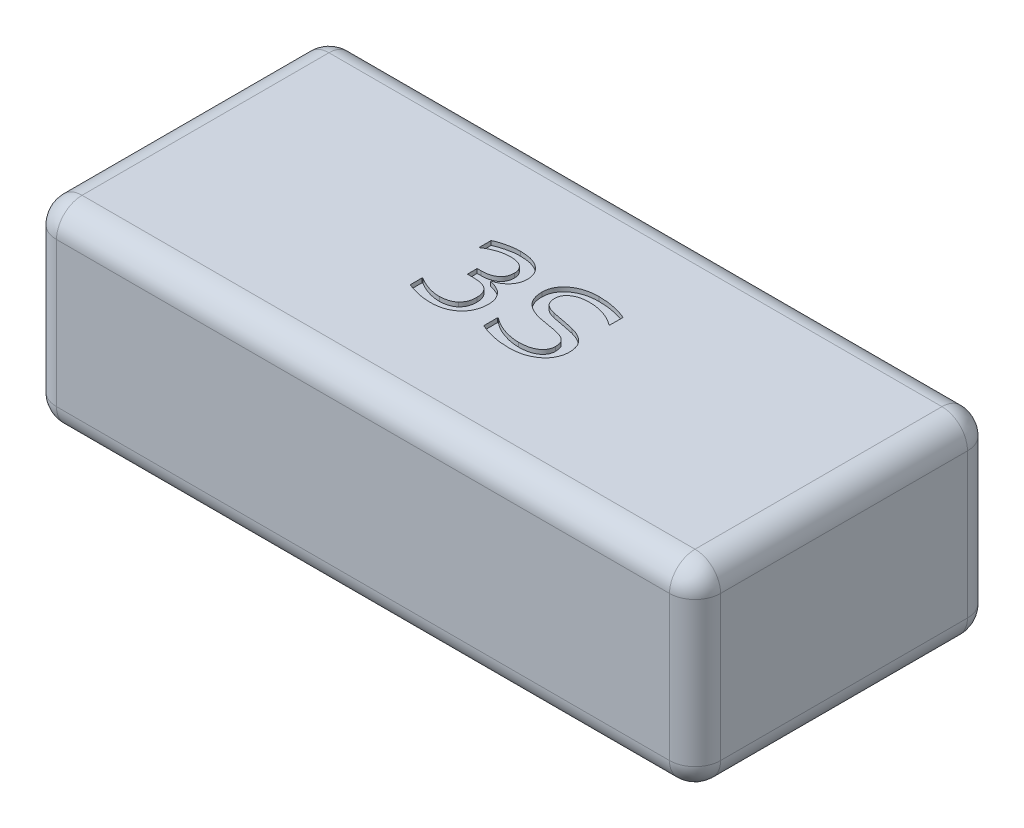
from build123d import *

# Parameters (mm, degrees)
SKICA1_W                 = 78
SKICA1_H                 = 35
P_IDAT_VYSUNUT_M1_DEPTH  = 23
ZAOBLIT1_R               = 3
ODEBRAT_VYSUNUT_M1_DEPTH = 0.5


with BuildPart() as part:
    # Skica1 → Přidat vysunutím1 (new body)
    with BuildSketch(Plane(origin=(0, 0, 0), x_dir=(1, 0, 0), z_dir=(0, 1, 0))):
        Rectangle(SKICA1_W, SKICA1_H)
    extrude(amount=P_IDAT_VYSUNUT_M1_DEPTH)

    # Zaoblit1
    zaoblit1_edges = [part.edges().sort_by_distance(p)[0] for p in [
        (39, 23, 0),
        (0, 23, -17.5),
        (-39, 23, 0),
        (0, 0, -17.5),
        (39, 0, 0),
        (0, 0, 17.5),
        (-39, 0, 0),
        (0, 23, 17.5),
        (-39, 11.5, -17.5),
        (39, 11.5, -17.5),
        (39, 11.5, 17.5),
        (-39, 11.5, 17.5),
    ]]
    fillet(zaoblit1_edges, radius=ZAOBLIT1_R)

    # Skica2 → Odebrat vysunutím1 (cut)
    with BuildSketch(Plane(origin=(0, 23, 0), x_dir=(1, 0, 0), z_dir=(0, 1, 0))):
        with BuildLine():
            add(Edge.make_bspline(
                [(-1.782361882, 0.073352781), (-1.729838113, 0.022972497), (-1.623845128, -0.078694937), (-1.483543013, -0.252135199), (-1.358427222, -0.443985844), (-1.246194522, -0.654552847), (-1.152930789, -0.891803328), (-1.089399078, -1.159962089), (-1.052580916, -1.45977402), (-1.047363786, -1.669680055), (-1.04462454, -1.77989089)],
                knots=[0, 0, 0, 0, 0.000218174, 0.000440275, 0.000667383, 0.000904494, 0.001154987, 0.001429858, 0.001728906, 0.002059496, 0.002059496, 0.002059496, 0.002059496], degree=3))
            add(Edge.make_bspline(
                [(-1.04462454, -1.77989089), (-1.04774886, -1.8921126), (-1.053877005, -2.112228024), (-1.099746924, -2.436079367), (-1.179307124, -2.74468389), (-1.287933389, -3.038431867), (-1.425672214, -3.313798537), (-1.586109658, -3.573369059), (-1.774449699, -3.813734665), (-1.918009686, -3.958201036), (-1.990035932, -4.030682029)],
                knots=[0, 0, 0, 0, 0.000336606, 0.000660231, 0.000978756, 0.001291037, 0.001597967, 0.001900914, 0.002205181, 0.002511544, 0.002511544, 0.002511544, 0.002511544], degree=3))
            add(Edge.make_bspline(
                [(-1.990035932, -4.030682029), (-2.076149985, -4.10584668), (-2.248294833, -4.256103313), (-2.535949464, -4.446597154), (-2.845932299, -4.604144599), (-3.175471353, -4.734119283), (-3.525652033, -4.828821148), (-3.891589009, -4.90094646), (-4.274804432, -4.942592237), (-4.535428248, -4.94775461), (-4.668042262, -4.950381396)],
                knots=[0, 0, 0, 0, 0.00034263, 0.00068493, 0.00103168, 0.001384275, 0.001745616, 0.002118381, 0.002502359, 0.002900147, 0.002900147, 0.002900147, 0.002900147], degree=3))
            add(Edge.make_bspline(
                [(-4.668042262, -4.950381396), (-4.806585854, -4.948331058), (-5.08221197, -4.944252006), (-5.494189971, -4.904176594), (-5.902454583, -4.84406869), (-6.301405607, -4.758904448), (-6.679648102, -4.659106133), (-7.027814217, -4.552309379), (-7.341453014, -4.443377238), (-7.535005846, -4.360686521), (-7.626903021, -4.3214257)],
                knots=[0, 0, 0, 0, 0.000415518, 0.000826653, 0.001240633, 0.00165298, 0.00204972, 0.002413838, 0.002745385, 0.003045106, 0.003045106, 0.003045106, 0.003045106], degree=3))
            Line((-7.626903021, -4.3214257), (-7.626903021, -2.92506494))
            Line((-7.626903021, -2.92506494), (-7.526032768, -2.92506494))
            add(Edge.make_bspline(
                [(-7.526032768, -2.92506494), (-7.427934696, -2.987061246), (-7.227847628, -3.113512855), (-6.906214232, -3.2815255), (-6.558648534, -3.431341152), (-6.192132096, -3.563442351), (-5.816538511, -3.67563096), (-5.440933092, -3.75065725), (-5.07227658, -3.802041745), (-4.828416218, -3.808126358), (-4.707599224, -3.81114089)],
                knots=[0, 0, 0, 0, 0.000348034, 0.000709872, 0.001087226, 0.001482638, 0.001878207, 0.002261834, 0.002630802, 0.002993094, 0.002993094, 0.002993094, 0.002993094], degree=3))
            add(Edge.make_bspline(
                [(-4.707599224, -3.81114089), (-4.636302695, -3.809871242), (-4.490544685, -3.807275586), (-4.269991091, -3.777159487), (-4.042635788, -3.733758831), (-3.813558262, -3.673770256), (-3.590518545, -3.597486405), (-3.386241544, -3.499615637), (-3.201703855, -3.388647594), (-3.095860886, -3.297735916), (-3.04422897, -3.253387725)],
                knots=[0, 0, 0, 0, 0.000213754, 0.000436997, 0.000666632, 0.000907937, 0.001146889, 0.001372485, 0.001586541, 0.001790413, 0.001790413, 0.001790413, 0.001790413], degree=3))
            add(Edge.make_bspline(
                [(-3.04422897, -3.253387725), (-2.994855417, -3.203720234), (-2.898015627, -3.106303923), (-2.776199302, -2.943686892), (-2.669677936, -2.7773926), (-2.582488215, -2.600151407), (-2.516394314, -2.405458874), (-2.469871319, -2.189862085), (-2.442588135, -1.950680851), (-2.438936736, -1.783920527), (-2.437029603, -1.696821269)],
                knots=[0, 0, 0, 0, 0.000209857, 0.000411607, 0.000608052, 0.000801771, 0.001002549, 0.001223298, 0.00146225, 0.001723513, 0.001723513, 0.001723513, 0.001723513], degree=3))
            add(Edge.make_bspline(
                [(-2.437029603, -1.696821269), (-2.43838445, -1.610976018), (-2.440991167, -1.445810191), (-2.475721239, -1.210676021), (-2.527682247, -0.997585145), (-2.604202201, -0.808255684), (-2.696990081, -0.638179088), (-2.808801919, -0.489029945), (-2.936172633, -0.357936449), (-3.033263906, -0.286654307), (-3.081808084, -0.251014307)],
                knots=[0, 0, 0, 0, 0.00025731, 0.000495064, 0.00071141, 0.00091378, 0.001105886, 0.001291013, 0.001471431, 0.001651839, 0.001651839, 0.001651839, 0.001651839], degree=3))
            add(Edge.make_bspline(
                [(-3.081808084, -0.251014307), (-3.134449508, -0.217341413), (-3.240842552, -0.149285469), (-3.418327359, -0.070612337), (-3.610544754, -0.00738885), (-3.892614646, 0.0550933), (-4.272294164, 0.101402738), (-4.582857772, 0.10899163), (-4.743200489, 0.112909743)],
                knots=[0, 0, 0, 0, 0.000187239, 0.000378426, 0.000580448, 0.000793477, 0.001244136, 0.00172516, 0.00172516, 0.00172516, 0.00172516], degree=3))
            Line((-4.743200489, 0.112909743), (-5.348422008, 0.112909743))
            Line((-5.348422008, 0.112909743), (-5.348422008, 1.25215025))
            Line((-5.348422008, 1.25215025), (-4.887583401, 1.25215025))
            add(Edge.make_bspline(
                [(-4.887583401, 1.25215025), (-4.805765797, 1.252823475), (-4.64643157, 1.254134536), (-4.414783099, 1.277732751), (-4.194908841, 1.309695556), (-3.988359918, 1.359909862), (-3.79346063, 1.420437884), (-3.611483311, 1.495626976), (-3.4437636, 1.587706783), (-3.286591505, 1.68938023), (-3.146081491, 1.805770162), (-3.023533371, 1.935813071), (-2.920653616, 2.079205771), (-2.834153796, 2.234608124), (-2.769072018, 2.403846436), (-2.72426586, 2.585320709), (-2.695792507, 2.778815866), (-2.692097538, 2.912120631), (-2.69019416, 2.98078949)],
                knots=[0, 0, 0, 0, 0.000245325, 0.000477754, 0.0006979, 0.000911379, 0.001114675, 0.001309721, 0.001500878, 0.001687939, 0.001870523, 0.002046829, 0.00222249, 0.002398652, 0.002578995, 0.002764639, 0.002958478, 0.003164412, 0.003164412, 0.003164412, 0.003164412], degree=3))
            add(Edge.make_bspline(
                [(-2.69019416, 2.98078949), (-2.692172708, 3.041537268), (-2.696001162, 3.159083085), (-2.723391631, 3.330342307), (-2.773490133, 3.488875325), (-2.84112444, 3.636111755), (-2.924760187, 3.771683129), (-3.023907947, 3.895115575), (-3.139652049, 4.004803849), (-3.226090759, 4.0669285), (-3.269703654, 4.098273667)],
                knots=[0, 0, 0, 0, 0.000182231, 0.000352613, 0.000518387, 0.000679457, 0.000837536, 0.00099507, 0.001153162, 0.001314159, 0.001314159, 0.001314159, 0.001314159], degree=3))
            add(Edge.make_bspline(
                [(-3.269703654, 4.098273667), (-3.317325084, 4.126899122), (-3.412258098, 4.183963783), (-3.563631564, 4.252793959), (-3.719832344, 4.308336058), (-3.940695438, 4.364799078), (-4.241239745, 4.407018605), (-4.488569857, 4.413368795), (-4.618596059, 4.416707212)],
                knots=[0, 0, 0, 0, 0.000166574, 0.000332065, 0.000497839, 0.000663341, 0.00101522, 0.001405263, 0.001405263, 0.001405263, 0.001405263], degree=3))
            add(Edge.make_bspline(
                [(-4.618596059, 4.416707212), (-4.725530711, 4.414024232), (-4.944203097, 4.408537764), (-5.276387423, 4.363043414), (-5.618227682, 4.288191652), (-5.967219577, 4.189325563), (-6.315090875, 4.05967434), (-6.658068241, 3.910864785), (-6.989683493, 3.734220674), (-7.200580006, 3.598692914), (-7.306491629, 3.530631262)],
                knots=[0, 0, 0, 0, 0.00032071, 0.000655826, 0.001003798, 0.00137002, 0.001742959, 0.002116688, 0.002490967, 0.00286855, 0.00286855, 0.00286855, 0.00286855], degree=3))
            Line((-7.306491629, 3.530631262), (-7.373738464, 3.530631262))
            Line((-7.373738464, 3.530631262), (-7.373738464, 4.926992022))
            add(Edge.make_bspline(
                [(-7.373738464, 4.926992022), (-7.288493829, 4.96631843), (-7.107368847, 5.049877883), (-6.809074611, 5.159437281), (-6.471065405, 5.262462019), (-6.102087658, 5.361886117), (-5.716038907, 5.449233834), (-5.327374326, 5.508923974), (-4.945145464, 5.549588989), (-4.692538159, 5.553838656), (-4.567172008, 5.555947718)],
                knots=[0, 0, 0, 0, 0.00028155, 0.000598228, 0.000952313, 0.001341406, 0.001744504, 0.002138935, 0.002520536, 0.002896515, 0.002896515, 0.002896515, 0.002896515], degree=3))
            add(Edge.make_bspline(
                [(-4.567172008, 5.555947718), (-4.449114007, 5.554656958), (-4.219949465, 5.552151441), (-3.887014973, 5.526341668), (-3.576014964, 5.482819486), (-3.284083234, 5.424220291), (-3.010078297, 5.345084827), (-2.750682888, 5.245325235), (-2.50486951, 5.12611327), (-2.352433603, 5.028707923), (-2.276823907, 4.980393921)],
                knots=[0, 0, 0, 0, 0.000354123, 0.000687395, 0.001000951, 0.00129575, 0.001579928, 0.00185541, 0.002128732, 0.002397727, 0.002397727, 0.002397727, 0.002397727], degree=3))
            add(Edge.make_bspline(
                [(-2.276823907, 4.980393921), (-2.199403259, 4.924997503), (-2.047943911, 4.816624538), (-1.851175197, 4.62305402), (-1.681012749, 4.415035056), (-1.542132605, 4.187814436), (-1.431415384, 3.94299795), (-1.35235058, 3.679147313), (-1.306832427, 3.395076543), (-1.300859756, 3.199836736), (-1.297789097, 3.099460376)],
                knots=[0, 0, 0, 0, 0.000285208, 0.000557958, 0.00082515, 0.001089739, 0.001354423, 0.001629116, 0.001913631, 0.00221468, 0.00221468, 0.00221468, 0.00221468], degree=3))
            add(Edge.make_bspline(
                [(-1.297789097, 3.099460376), (-1.299999366, 3.02951396), (-1.304351321, 2.891791517), (-1.329597478, 2.68815606), (-1.376098234, 2.492646166), (-1.437337923, 2.302106187), (-1.518054737, 2.119085636), (-1.61847153, 1.943526774), (-1.735705783, 1.774831469), (-1.869138182, 1.614468659), (-2.014936462, 1.464653666), (-2.169332302, 1.329104739), (-2.327666713, 1.204672388), (-2.494439727, 1.097182502), (-2.669289187, 1.007756015), (-2.847689477, 0.926614894), (-3.033862225, 0.86305942), (-3.161946941, 0.833718286), (-3.226190996, 0.819001516)],
                knots=[0, 0, 0, 0, 0.000209885, 0.000413257, 0.000614279, 0.000811926, 0.001012947, 0.001213131, 0.001417778, 0.001628472, 0.001838273, 0.002044245, 0.002244428, 0.002441936, 0.002638332, 0.002833127, 0.003029522, 0.003227159, 0.003227159, 0.003227159, 0.003227159], degree=3))
            Line((-3.226190996, 0.819001516), (-3.226190996, 0.724064807))
            add(Edge.make_bspline(
                [(-3.226190996, 0.724064807), (-3.170627411, 0.713663156), (-3.053880131, 0.691807755), (-2.875329823, 0.640993631), (-2.684363945, 0.577622448), (-2.486921648, 0.499830881), (-2.289927635, 0.411118738), (-2.104354753, 0.310847002), (-1.933737493, 0.200391356), (-1.832326708, 0.115284637), (-1.782361882, 0.073352781)],
                knots=[0, 0, 0, 0, 0.000169507, 0.00035616, 0.000556304, 0.000773003, 0.000992508, 0.001204027, 0.00140535, 0.001600877, 0.001600877, 0.001600877, 0.001600877], degree=3))
        make_face()
        with BuildLine():
            add(Edge.make_bspline(
                [(8.575628624, -1.87284975), (8.571802335, -1.971256946), (8.564128606, -2.168615264), (8.513955827, -2.464579301), (8.42484972, -2.757345257), (8.306972164, -3.046302901), (8.161211464, -3.325022158), (7.979763381, -3.580385288), (7.777628956, -3.819965693), (7.619018375, -3.956214465), (7.539236219, -4.024748484)],
                knots=[0, 0, 0, 0, 0.000295236, 0.000592105, 0.000897489, 0.001211518, 0.001527393, 0.001838494, 0.002149777, 0.002464827, 0.002464827, 0.002464827, 0.002464827], degree=3))
            add(Edge.make_bspline(
                [(7.539236219, -4.024748484), (7.446819168, -4.09502879), (7.26111215, -4.236253226), (6.957030788, -4.419152715), (6.630564547, -4.57588552), (6.281219737, -4.713175686), (5.901196754, -4.820362121), (5.486800498, -4.896374004), (5.035625383, -4.941645911), (4.722888958, -4.947396944), (4.560596979, -4.950381396)],
                knots=[0, 0, 0, 0, 0.000348124, 0.000699536, 0.001062216, 0.001433551, 0.001824225, 0.002244731, 0.002696001, 0.003182809, 0.003182809, 0.003182809, 0.003182809], degree=3))
            add(Edge.make_bspline(
                [(4.560596979, -4.950381396), (4.384492655, -4.948423761), (4.04109028, -4.944606384), (3.539384315, -4.905631187), (3.065122166, -4.845729103), (2.613256955, -4.759855655), (2.174433677, -4.64593085), (1.73653348, -4.511241774), (1.293342082, -4.356084365), (1.001837703, -4.233322355), (0.854109637, -4.171109244)],
                knots=[0, 0, 0, 0, 0.000528219, 0.001030023, 0.00150865, 0.00196172, 0.002408806, 0.002868024, 0.003335943, 0.003816723, 0.003816723, 0.003816723, 0.003816723], degree=3))
            Line((0.854109637, -4.171109244), (0.854109637, -2.545318105))
            Line((0.854109637, -2.545318105), (0.949046346, -2.545318105))
            add(Edge.make_bspline(
                [(0.949046346, -2.545318105), (1.078391891, -2.643623536), (1.338461345, -2.841281984), (1.765969784, -3.090646944), (2.219741556, -3.309983593), (2.698233811, -3.487698594), (3.181833345, -3.631902225), (3.658469122, -3.731121815), (4.118833845, -3.800314264), (4.421908873, -3.80757932), (4.570486219, -3.81114089)],
                knots=[0, 0, 0, 0, 0.000486993, 0.000979175, 0.001481646, 0.001997405, 0.00250872, 0.002994003, 0.003457208, 0.003902663, 0.003902663, 0.003902663, 0.003902663], degree=3))
            add(Edge.make_bspline(
                [(4.570486219, -3.81114089), (4.670732225, -3.809517389), (4.865534495, -3.806362535), (5.149637377, -3.78497088), (5.416390175, -3.747262259), (5.6666042, -3.696879161), (5.899510418, -3.629462761), (6.115143549, -3.546558068), (6.314040672, -3.449763355), (6.494965011, -3.338610358), (6.656977019, -3.215543426), (6.795893709, -3.079202563), (6.917237892, -2.936518117), (7.014245379, -2.780991843), (7.090515263, -2.615554342), (7.143034753, -2.439671083), (7.178960287, -2.254714905), (7.181784943, -2.12750971), (7.183223561, -2.062723168)],
                knots=[0, 0, 0, 0, 0.000300737, 0.000584405, 0.000854046, 0.001108505, 0.001349486, 0.001580522, 0.001800775, 0.002012109, 0.002216632, 0.002409652, 0.002595022, 0.00277721, 0.002957758, 0.003139817, 0.003326804, 0.003520886, 0.003520886, 0.003520886, 0.003520886], degree=3))
            add(Edge.make_bspline(
                [(7.183223561, -2.062723168), (7.181773488, -2.008640518), (7.178957059, -1.903597611), (7.166186968, -1.751333392), (7.140740003, -1.609446448), (7.102404477, -1.479645068), (7.058309208, -1.359108571), (6.999523981, -1.251724449), (6.932953396, -1.153930245), (6.825755405, -1.03770902), (6.66445558, -0.907480291), (6.432298051, -0.77581538), (6.160149327, -0.657953674), (5.95976688, -0.601298646), (5.854109637, -0.5714257)],
                knots=[0, 0, 0, 0, 0.000162292, 0.000315214, 0.000457976, 0.000593816, 0.000720907, 0.000842138, 0.000960098, 0.001074915, 0.001315246, 0.001578486, 0.00187351, 0.002202583, 0.002202583, 0.002202583, 0.002202583], degree=3))
            add(Edge.make_bspline(
                [(5.854109637, -0.5714257), (5.677957344, -0.527284345), (5.313512692, -0.435959502), (4.738024667, -0.346295768), (4.125729997, -0.248878662), (3.70789079, -0.165449216), (3.492559004, -0.122454181)],
                knots=[0, 0, 0, 0, 0.000544512, 0.001126551, 0.001745974, 0.002404624, 0.002404624, 0.002404624, 0.002404624], degree=3))
            add(Edge.make_bspline(
                [(3.492559004, -0.122454181), (3.384107921, -0.098037639), (3.172256061, -0.050341575), (2.868607498, 0.040898527), (2.586449092, 0.143605765), (2.325624058, 0.258335901), (2.086535342, 0.386090692), (1.868785197, 0.527642867), (1.672683591, 0.681059688), (1.498798619, 0.849122678), (1.346001452, 1.029088345), (1.214327548, 1.222829167), (1.103049774, 1.429648607), (1.012277518, 1.649849171), (0.940733358, 1.882904091), (0.889395879, 2.128435058), (0.859554436, 2.387351767), (0.85595248, 2.564044528), (0.854109637, 2.654444553)],
                knots=[0, 0, 0, 0, 0.000333413, 0.000651299, 0.000950393, 0.00123375, 0.001505414, 0.001762702, 0.002011981, 0.00225117, 0.002486941, 0.002718991, 0.002952611, 0.003190258, 0.003432373, 0.003682959, 0.003941785, 0.004212931, 0.004212931, 0.004212931, 0.004212931], degree=3))
            add(Edge.make_bspline(
                [(0.854109637, 2.654444553), (0.856647202, 2.758201044), (0.861642155, 2.96243572), (0.916175387, 3.2607487), (0.99777036, 3.546566285), (1.118157658, 3.816238165), (1.26979425, 4.072037627), (1.455546533, 4.313235968), (1.676264533, 4.5383088), (1.928106146, 4.747281036), (2.203731578, 4.937405102), (2.50159006, 5.102516635), (2.816442845, 5.243207734), (3.150111548, 5.35784649), (3.501421779, 5.447014496), (3.871240674, 5.508994978), (4.258357726, 5.55052501), (4.522905835, 5.554119031), (4.657511536, 5.555947718)],
                knots=[0, 0, 0, 0, 0.000310925, 0.000612026, 0.000906805, 0.001200807, 0.001495234, 0.001797074, 0.002111776, 0.002438959, 0.002777454, 0.003114792, 0.003459199, 0.003810722, 0.004171938, 0.004545222, 0.004934894, 0.005338549, 0.005338549, 0.005338549, 0.005338549], degree=3))
            add(Edge.make_bspline(
                [(4.657511536, 5.555947718), (4.83163302, 5.553896651), (5.17370515, 5.549867206), (5.675530084, 5.511512287), (6.155817733, 5.449326466), (6.612070501, 5.35912709), (7.044465426, 5.25208901), (7.452328334, 5.133626404), (7.835178107, 5.004586904), (8.077700994, 4.904541409), (8.195881789, 4.85578949)],
                knots=[0, 0, 0, 0, 0.000522287, 0.001026064, 0.001508869, 0.001974341, 0.002420463, 0.00284483, 0.003248258, 0.003631695, 0.003631695, 0.003631695, 0.003631695], degree=3))
            Line((8.195881789, 4.85578949), (8.195881789, 3.277466705))
            Line((8.195881789, 3.277466705), (8.10094508, 3.277466705))
            add(Edge.make_bspline(
                [(8.10094508, 3.277466705), (7.998486781, 3.358365232), (7.786850846, 3.525467707), (7.423489765, 3.736823092), (7.017886551, 3.930218818), (6.573165062, 4.099175305), (6.10523285, 4.241365483), (5.623366171, 4.341639059), (5.136576017, 4.405842744), (4.809344579, 4.413084477), (4.645644447, 4.416707212)],
                knots=[0, 0, 0, 0, 0.000391219, 0.000808095, 0.001257502, 0.001738318, 0.002233903, 0.002723055, 0.003213454, 0.003704359, 0.003704359, 0.003704359, 0.003704359], degree=3))
            add(Edge.make_bspline(
                [(4.645644447, 4.416707212), (4.557268529, 4.414902922), (4.384911499, 4.411384066), (4.133097305, 4.392318251), (3.894921954, 4.357388499), (3.670845445, 4.304525249), (3.458273253, 4.243017873), (3.260019486, 4.163249629), (3.074912112, 4.069697138), (2.903312993, 3.964219413), (2.750324172, 3.846063907), (2.615061754, 3.720741084), (2.502226374, 3.585395377), (2.407156744, 3.44237189), (2.3366608, 3.289022661), (2.284309974, 3.128563216), (2.251486903, 2.95970975), (2.248188674, 2.843807322), (2.2465147, 2.784982528)],
                knots=[0, 0, 0, 0, 0.00026515, 0.000517114, 0.000757111, 0.000986447, 0.001207339, 0.001420359, 0.001626455, 0.001828979, 0.002023614, 0.002205511, 0.002381005, 0.002551066, 0.002719183, 0.002885558, 0.003056627, 0.003232933, 0.003232933, 0.003232933, 0.003232933], degree=3))
            add(Edge.make_bspline(
                [(2.2465147, 2.784982528), (2.249761341, 2.685079677), (2.255979644, 2.493735424), (2.317977413, 2.223699535), (2.419082228, 1.986194139), (2.540426505, 1.81607434), (2.660787968, 1.699442078), (2.765877765, 1.61622307), (2.887395564, 1.539225854), (3.024023593, 1.468539339), (3.175709217, 1.403456267), (3.341812684, 1.341884727), (3.524419916, 1.287032698), (3.651970164, 1.254931727), (3.718033688, 1.238305313)],
                knots=[0, 0, 0, 0, 0.000299309, 0.000573268, 0.000825705, 0.001069422, 0.001193901, 0.001327651, 0.001470851, 0.00162478, 0.001788655, 0.001965747, 0.00215595, 0.002360311, 0.002360311, 0.002360311, 0.002360311], degree=3))
            add(Edge.make_bspline(
                [(3.718033688, 1.238305313), (3.798433142, 1.22165897), (3.973539652, 1.185403961), (4.259703614, 1.130123776), (4.590565965, 1.068839467), (4.955496547, 1.006188307), (5.328094262, 0.943092382), (5.682814916, 0.873534556), (6.006633452, 0.803037735), (6.211546205, 0.75220129), (6.3090147, 0.728020503)],
                knots=[0, 0, 0, 0, 0.000246312, 0.000536456, 0.000874344, 0.001255761, 0.00164726, 0.002007999, 0.002340089, 0.002641346, 0.002641346, 0.002641346, 0.002641346], degree=3))
            add(Edge.make_bspline(
                [(6.3090147, 0.728020503), (6.400312916, 0.702686746), (6.578425378, 0.653263461), (6.834416756, 0.563375732), (7.073776708, 0.465100412), (7.295799593, 0.357180631), (7.498238308, 0.236985283), (7.686093097, 0.110836818), (7.855472768, -0.02699158), (8.007627099, -0.175249893), (8.14454562, -0.333365795), (8.258862419, -0.510170614), (8.358793856, -0.699508478), (8.436951933, -0.905956373), (8.501695496, -1.125769846), (8.542716977, -1.36205657), (8.572655446, -1.612326237), (8.574619284, -1.784406692), (8.575628624, -1.87284975)],
                knots=[0, 0, 0, 0, 0.000284178, 0.000554398, 0.000813345, 0.001060133, 0.001294189, 0.001519107, 0.001738426, 0.001948227, 0.002155891, 0.002364346, 0.002578429, 0.00279697, 0.003025452, 0.003264804, 0.003515547, 0.003780697, 0.003780697, 0.003780697, 0.003780697], degree=3))
        make_face()
    extrude(amount=-ODEBRAT_VYSUNUT_M1_DEPTH, mode=Mode.SUBTRACT)


solid = part.part
